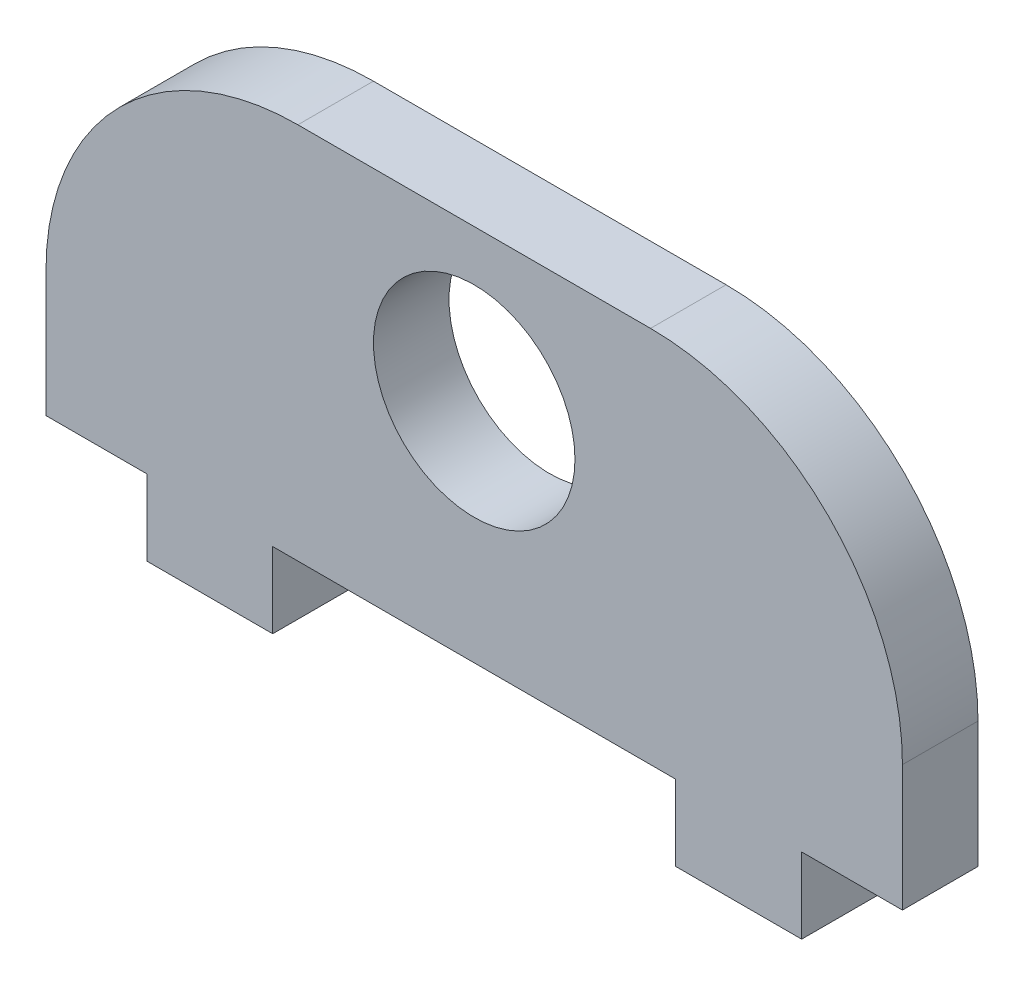
from build123d import *

# Parameters (mm, degrees)
SKETCH1_R           = 4
BOSS_EXTRUDE1_DEPTH = 3
FILLET1_R           = 10


with BuildPart() as part:
    # Sketch1 → Boss-Extrude1 (new body)
    with BuildSketch(Plane.XY):
        Polygon((-17, -7.5), (-13, -7.5), (-13, -10.5), (-8, -10.5), (-8, -7.5), (8, -7.5), (8, -10.5), (13, -10.5), (13, -7.5), (17, -7.5), (17, 7.5), (-17, 7.5), align=None)
        with Locations((0, 1.5)):
            Circle(SKETCH1_R, mode=Mode.SUBTRACT)
    extrude(amount=BOSS_EXTRUDE1_DEPTH)

    # Fillet1
    fillet1_edges = [part.edges().sort_by_distance(p)[0] for p in [
        (-17, 7.5, 1.5),
        (17, 7.5, 1.5),
    ]]
    fillet(fillet1_edges, radius=FILLET1_R)


solid = part.part
